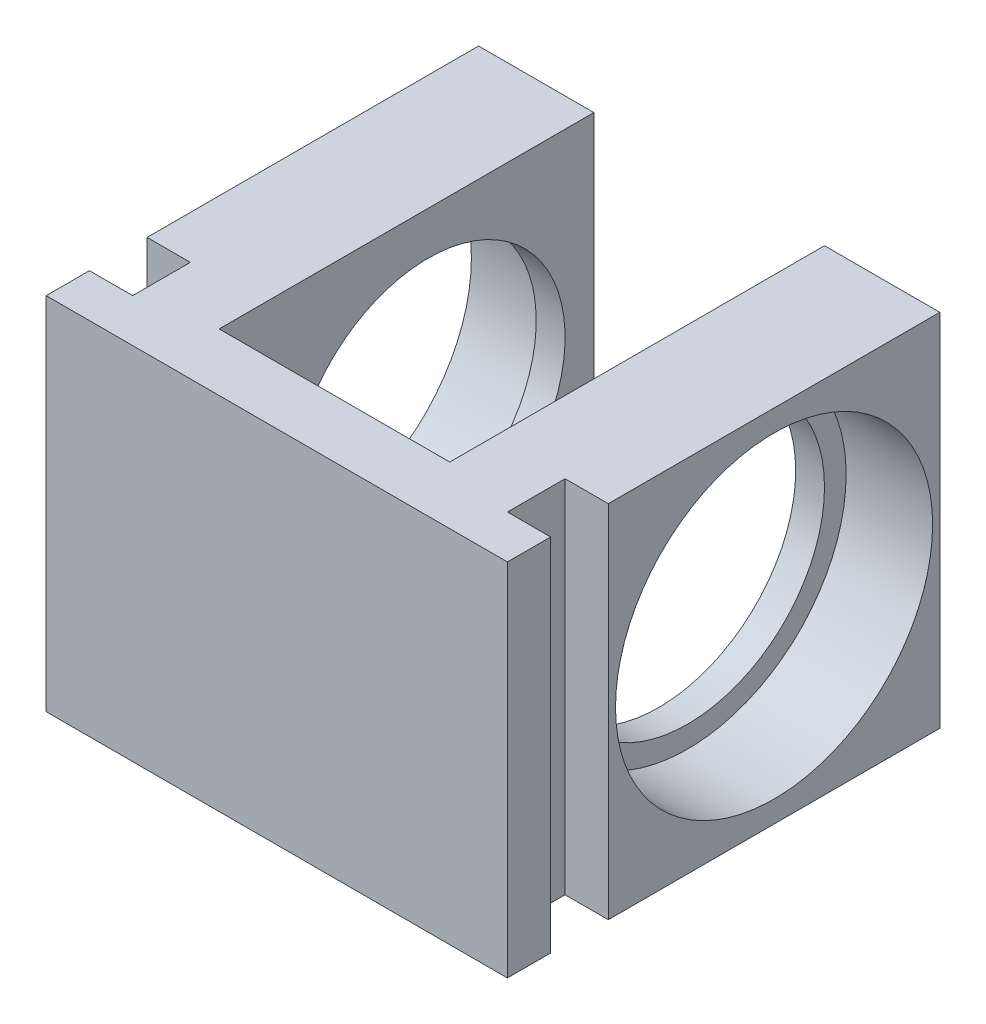
from build123d import *

# Parameters (mm, degrees)
AUFSATZ_LINEAR_AUSTRAGEN1_DEPTH = 25
SKIZZE2_W                       = 3
SKIZZE2_H                       = 4
SCHNITT_LINEAR_AUSTRAGEN1_DEPTH = 25
SKIZZE3_R                       = 9.5
SCHNITT_LINEAR_AUSTRAGEN2_DEPTH = 35
SKIZZE4_R                       = 11
SCHNITT_LINEAR_AUSTRAGEN3_DEPTH = 6
SKIZZE5_R                       = 11
SCHNITT_LINEAR_AUSTRAGEN4_DEPTH = 6


with BuildPart() as part:
    # Skizze1 → Aufsatz-Linear austragen1 (new body)
    with BuildSketch(Plane(origin=(0, 0, 0), x_dir=(1, 0, 0), z_dir=(0, 1, 0))):
        Polygon((-8, 0), (-8, 26), (-16, 26), (-16, -4), (16, -4), (16, 26), (8, 26), (8, 0), align=None)
    extrude(amount=AUFSATZ_LINEAR_AUSTRAGEN1_DEPTH)

    # Skizze2 → Schnitt-Linear austragen1 (cut)
    with BuildSketch(Plane.XZ):
        with Locations((14.5, -1)):
            Rectangle(SKIZZE2_W, SKIZZE2_H)
        with Locations((-14.5, -1)):
            Rectangle(SKIZZE2_W, SKIZZE2_H)
    extrude(amount=-SCHNITT_LINEAR_AUSTRAGEN1_DEPTH, mode=Mode.SUBTRACT)

    # Skizze3 → Schnitt-Linear austragen2 (cut)
    with BuildSketch(Plane.ZY.offset(16)):
        with Locations((-14.5, 12.5)):
            Circle(SKIZZE3_R)
    extrude(amount=-SCHNITT_LINEAR_AUSTRAGEN2_DEPTH, mode=Mode.SUBTRACT)

    # Skizze4 → Schnitt-Linear austragen3 (cut)
    with BuildSketch(Plane.ZY.offset(16)):
        with Locations((-14.5, 12.5)):
            Circle(SKIZZE4_R)
    extrude(amount=-SCHNITT_LINEAR_AUSTRAGEN3_DEPTH, mode=Mode.SUBTRACT)

    # Skizze5 → Schnitt-Linear austragen4 (cut)
    with BuildSketch(Plane(origin=(16, 0, 0), x_dir=(0, 0, -1), z_dir=(1, 0, 0))):
        with Locations((14.5, 12.5)):
            Circle(SKIZZE5_R)
    extrude(amount=-SCHNITT_LINEAR_AUSTRAGEN4_DEPTH, mode=Mode.SUBTRACT)


solid = part.part
